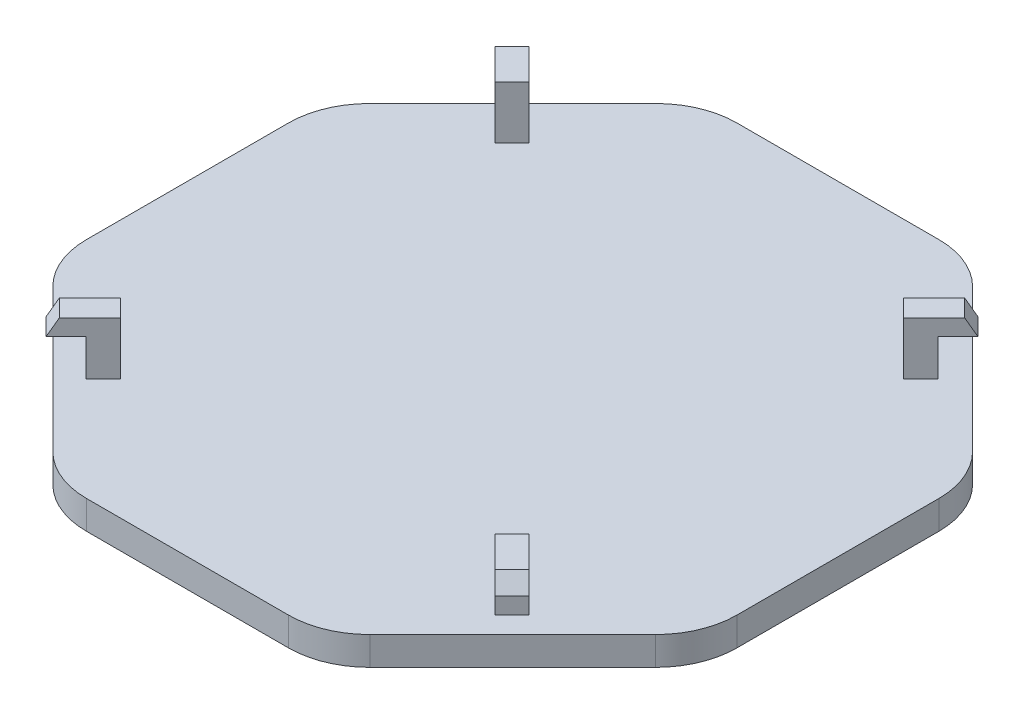
from build123d import *

# Parameters (mm, degrees)
BOSS_EXTRUDE1_DEPTH = 3.5
FILLET1_R           = 10
BOSS_EXTRUDE2_DEPTH = 1.5
CIRPATTERN1_COUNT   = 4


with BuildPart() as part:
    # Sketch1 → Boss-Extrude1 (new body)
    with BuildSketch(Plane(origin=(0, 0, 0), x_dir=(1, 0, 0), z_dir=(0, 1, 0))):
        Polygon((40, 16.568542495), (16.568542495, 40), (-16.568542495, 40), (-40, 16.568542495), (-40, -16.568542495), (-16.568542495, -40), (16.568542495, -40), (40, -16.568542495), align=None)
    extrude(amount=BOSS_EXTRUDE1_DEPTH)

    # Fillet1
    fillet1_edges = [part.edges().sort_by_distance(p)[0] for p in [
        (40, 1.75, 16.568542495),
        (16.568542495, 1.75, 40),
        (-16.568542495, 1.75, 40),
        (-40, 1.75, 16.568542495),
        (-40, 1.75, -16.568542495),
        (-16.568542495, 1.75, -40),
        (16.568542495, 1.75, -40),
        (40, 1.75, -16.568542495),
    ]]
    fillet(fillet1_edges, radius=FILLET1_R)

    # Sketch3 → Boss-Extrude2 (add, symmetric)
    with BuildSketch(Plane(origin=(0, 0, 0), x_dir=(-0.707106781, 0, 0.707106781), z_dir=(-0.707106781, 0, -0.707106781))):
        Polygon((-33.97, 3.5), (-33.97, 10), (-39.315299462, 10), (-40.47, 8), (-36.97, 8), (-36.97, 3.5), align=None)
    boss_extrude2 = extrude(amount=BOSS_EXTRUDE2_DEPTH, both=True)

    # CirPattern1: Boss-Extrude2 ×4 about axis
    cirpattern1_axis = Axis((-0.042786503, 0, 0.042786503), (0, 1, 0))
    for i in range(1, CIRPATTERN1_COUNT):
        add(boss_extrude2.rotate(cirpattern1_axis, i * 360 / CIRPATTERN1_COUNT))


solid = part.part
